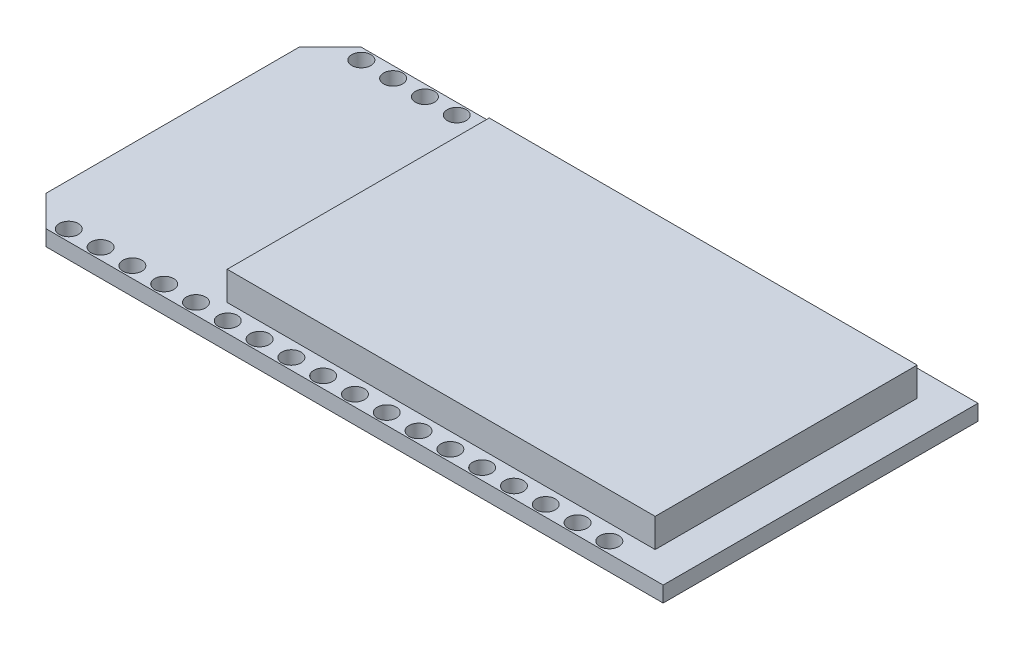
from build123d import *

# Parameters (mm, degrees)
ESQUISSE1_W             = 51.75
ESQUISSE1_H             = 25.15
BOSS_EXTRU_1_DEPTH      = 1.25
ENL_V_MAT_EXTRU_1_DEPTH = 1.25
ESQUISSE3_R             = 0.762
ENL_V_MAT_EXTRU_2_DEPTH = 1.25
ESQUISSE4_W             = 34.186682017
ESQUISSE4_H             = 20.933463699
BOSS_EXTRU_2_DEPTH      = 2.3


with BuildPart() as part:
    # Esquisse1 → Boss.-Extru.1 (new body)
    with BuildSketch(Plane(origin=(0, 0, 0), x_dir=(1, 0, 0), z_dir=(0, 1, 0))):
        with Locations((25.875, 12.575)):
            Rectangle(ESQUISSE1_W, ESQUISSE1_H)
    extrude(amount=BOSS_EXTRU_1_DEPTH)

    # Esquisse2 → Enlèv. mat.-Extru.1 (cut)
    with BuildSketch(Plane(origin=(0, 1.25, 0), x_dir=(1, 0, 0), z_dir=(0, 1, 0))):
        Polygon((0, 25.15), (2.45, 25.15), (0, 22.7), align=None)
        Polygon((0, 0), (2.45, 0), (0, 2.45), align=None)
    extrude(amount=-ENL_V_MAT_EXTRU_1_DEPTH, mode=Mode.SUBTRACT)

    # Esquisse3 → Enlèv. mat.-Extru.2 (cut)
    with BuildSketch(Plane(origin=(0, 1.25, 0), x_dir=(1, 0, 0), z_dir=(0, 1, 0))):
        with Locations((3.38, 24.26)):
            Circle(ESQUISSE3_R)
        with Locations((5.92, 24.26)):
            Circle(ESQUISSE3_R)
        with Locations((8.46, 24.26)):
            Circle(ESQUISSE3_R)
        with Locations((11, 24.26)):
            Circle(ESQUISSE3_R)
        with Locations((13.54, 24.26)):
            Circle(ESQUISSE3_R)
        with Locations((16.08, 24.26)):
            Circle(ESQUISSE3_R)
        with Locations((18.62, 24.26)):
            Circle(ESQUISSE3_R)
        with Locations((21.16, 24.26)):
            Circle(ESQUISSE3_R)
        with Locations((23.7, 24.26)):
            Circle(ESQUISSE3_R)
        with Locations((26.24, 24.26)):
            Circle(ESQUISSE3_R)
        with Locations((28.78, 24.26)):
            Circle(ESQUISSE3_R)
        with Locations((31.32, 24.26)):
            Circle(ESQUISSE3_R)
        with Locations((33.86, 24.26)):
            Circle(ESQUISSE3_R)
        with Locations((36.4, 24.26)):
            Circle(ESQUISSE3_R)
        with Locations((38.94, 24.26)):
            Circle(ESQUISSE3_R)
        with Locations((41.48, 24.26)):
            Circle(ESQUISSE3_R)
        with Locations((44.02, 24.26)):
            Circle(ESQUISSE3_R)
        with Locations((46.56, 24.26)):
            Circle(ESQUISSE3_R)
        with Locations((46.56, 0.89)):
            Circle(ESQUISSE3_R)
        with Locations((44.02, 0.89)):
            Circle(ESQUISSE3_R)
        with Locations((41.48, 0.89)):
            Circle(ESQUISSE3_R)
        with Locations((38.94, 0.89)):
            Circle(ESQUISSE3_R)
        with Locations((36.4, 0.89)):
            Circle(ESQUISSE3_R)
        with Locations((33.86, 0.89)):
            Circle(ESQUISSE3_R)
        with Locations((31.32, 0.89)):
            Circle(ESQUISSE3_R)
        with Locations((28.78, 0.89)):
            Circle(ESQUISSE3_R)
        with Locations((26.24, 0.89)):
            Circle(ESQUISSE3_R)
        with Locations((23.7, 0.89)):
            Circle(ESQUISSE3_R)
        with Locations((18.62, 0.89)):
            Circle(ESQUISSE3_R)
        with Locations((21.16, 0.89)):
            Circle(ESQUISSE3_R)
        with Locations((16.08, 0.89)):
            Circle(ESQUISSE3_R)
        with Locations((13.54, 0.89)):
            Circle(ESQUISSE3_R)
        with Locations((11, 0.89)):
            Circle(ESQUISSE3_R)
        with Locations((8.46, 0.89)):
            Circle(ESQUISSE3_R)
        with Locations((5.92, 0.89)):
            Circle(ESQUISSE3_R)
        with Locations((3.38, 0.89)):
            Circle(ESQUISSE3_R)
    extrude(amount=-ENL_V_MAT_EXTRU_2_DEPTH, mode=Mode.SUBTRACT)

    # Esquisse4 → Boss.-Extru.2 (add)
    with BuildSketch(Plane(origin=(0, 1.25, 0), x_dir=(1, 0, 0), z_dir=(0, 1, 0))):
        with Locations((31.885763085, 12.597978811)):
            Rectangle(ESQUISSE4_W, ESQUISSE4_H)
    extrude(amount=BOSS_EXTRU_2_DEPTH)


solid = part.part
